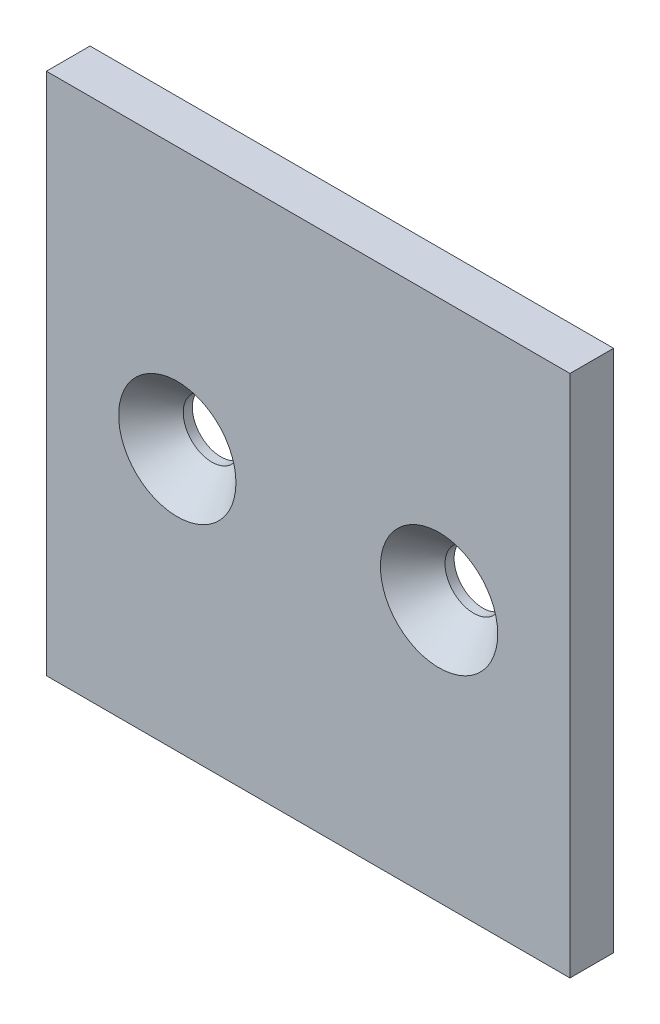
from build123d import *

# Parameters (mm, degrees)
SKETCH1_W           = 76.2
SKETCH1_H           = 76.2
SKETCH1_R           = 4.1656
BOSS_EXTRUDE1_DEPTH = 3.175
CUT_EXTRUDE1_START  = -5.0292
SKETCH2_R           = 4.1656
CUT_EXTRUDE1_DEPTH  = 6.0292
CUT_EXTRUDE1_TAPER  = -41


with BuildPart() as part:
    # Sketch1 → Boss-Extrude1 (new body, symmetric)
    with BuildSketch(Plane.XY):
        with Locations((38.1, 38.1)):
            Rectangle(SKETCH1_W, SKETCH1_H)
        with Locations((19.05, 38.1)):
            Circle(SKETCH1_R, mode=Mode.SUBTRACT)
        with Locations((57.15, 38.1)):
            Circle(SKETCH1_R, mode=Mode.SUBTRACT)
    extrude(amount=BOSS_EXTRUDE1_DEPTH, both=True)

    # Sketch2 → Cut-Extrude1 (cut, through all)
    with BuildSketch(Plane.XY.offset(3.175).offset(CUT_EXTRUDE1_START)):
        with Locations((19.05, 38.1)):
            Circle(SKETCH2_R)
        with Locations((57.15, 38.1)):
            Circle(SKETCH2_R)
    extrude(amount=CUT_EXTRUDE1_DEPTH, taper=CUT_EXTRUDE1_TAPER, mode=Mode.SUBTRACT)


solid = part.part
